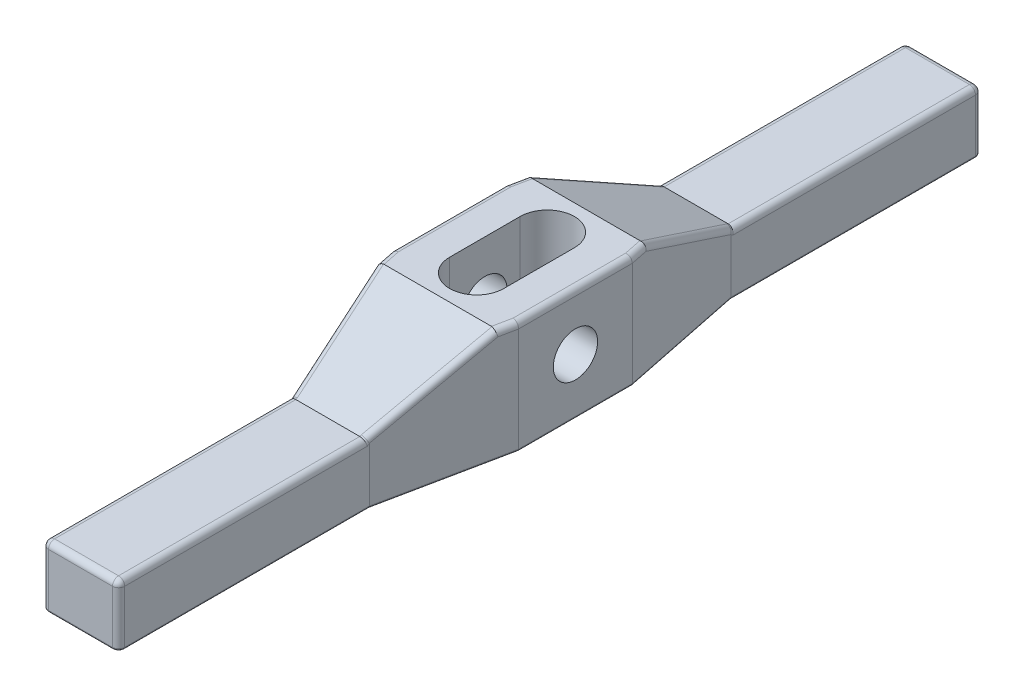
from build123d import *

# Parameters (mm, degrees)
EXTRUDE1_DEPTH     = 28.067
CUT_EXTRUDE1_DEPTH = 32.75
SKETCH3_R          = 5.54355
CUT_EXTRUDE2_DEPTH = 32.75
FILLET1_R          = 1.524
FILLET2_R          = 0.508
FILLET3_R          = 1.524


with BuildPart() as part:
    # Sketch1 → Extrude1 (new body)
    with BuildSketch(Plane(origin=(0, 0, 0), x_dir=(1, 0, 0), z_dir=(0, 1, 0))):
        Polygon((-9.525, 107.95), (9.525, 107.95), (9.525, 45.212), (15.875, 14.224508), (15.875, -14.224508), (9.525, -45.212), (9.525, -107.95), (-9.525, -107.95), (-9.525, -45.212), (-15.875, -14.224508), (-15.875, 14.224508), (-9.525, 45.212), align=None)
        with BuildLine():
            Line((-6.7818, 8.8265), (-6.7818, -8.8265))
            ThreePointArc((-6.7818, -8.8265), (0, -15.6083), (6.7818, -8.8265))
            Line((6.7818, -8.8265), (6.7818, 8.8265))
            ThreePointArc((6.7818, 8.8265), (0, 15.6083), (-6.7818, 8.8265))
        make_face(mode=Mode.SUBTRACT)
    extrude(amount=EXTRUDE1_DEPTH)

    # Sketch2 → Cut-Extrude1 (cut, through all)
    with BuildSketch(Plane(origin=(15.875, 0, 0), x_dir=(0, 0, -1), z_dir=(1, 0, 0))):
        Polygon((107.95, 28.067), (18.5674, 28.067), (46.074990269, 15.24), (107.95, 15.24), align=None)
        Polygon((-107.95, 15.24), (-107.95, 28.067), (-18.5674, 28.067), (-46.074990269, 15.24), align=None)
    extrude(amount=-CUT_EXTRUDE1_DEPTH, mode=Mode.SUBTRACT)

    # Sketch3 → Cut-Extrude2 (cut, through all)
    with BuildSketch(Plane(origin=(15.875, 0, 0), x_dir=(0, 0, -1), z_dir=(1, 0, 0))):
        with Locations((0, 13.9446)):
            Circle(SKETCH3_R)
    extrude(amount=-CUT_EXTRUDE2_DEPTH, mode=Mode.SUBTRACT)

    # Fillet1
    fillet1_edges = [part.edges().sort_by_distance(p)[0] for p in [
        (-9.525, 7.62, -107.95),
        (9.525, 7.62, -107.95),
        (9.525, 7.62, 107.95),
        (-9.525, 7.62, 107.95),
    ]]
    fillet(fillet1_edges, radius=FILLET1_R)

    # Fillet2
    fillet2_edges = [part.edges().sort_by_distance(p)[0] for p in [
        (-9.525, 0, -75.819),
        (9.525, 0, 75.819),
        (0, 0, 107.95),
        (0, 0, -107.95),
        (-9.078630735, 0, 107.503630735),
        (12.7, 0, -29.718254),
        (9.078630735, 0, 107.503630735),
        (9.078630735, 0, -107.503630735),
        (-9.078630735, 0, -107.503630735),
        (15.875, 0, 0),
        (12.7, 0, 29.718254),
        (-9.525, 0, 75.819),
        (-12.7, 0, 29.718254),
        (-15.875, 0, 0),
        (-12.7, 0, -29.718254),
        (9.525, 0, -75.819),
    ]]
    fillet(fillet2_edges, radius=FILLET2_R)

    # Fillet3
    fillet3_edges = [part.edges().sort_by_distance(p)[0] for p in [
        (0, 15.24, -107.95),
        (9.525, 15.24, -76.250495135),
        (9.078630735, 15.24, -107.503630735),
        (-9.078630735, 15.24, -107.503630735),
        (0, 15.24, 107.95),
        (-9.525, 15.24, 76.250495135),
        (-9.078630735, 15.24, 107.503630735),
        (9.078630735, 15.24, 107.503630735),
        (-15.875, 28.067, 0),
        (-15.430024263, 28.067, 16.395954),
        (15.875, 28.067, 0),
        (15.430024263, 28.067, -16.395954),
        (12.255024263, 21.854709486, -31.8897),
        (-15.430024263, 28.067, -16.395954),
        (-9.525, 15.24, -76.250495135),
        (-12.255024263, 21.854709486, -31.8897),
        (-9.525, 15.441209486, -45.643495135),
        (9.525, 15.441209486, -45.643495135),
        (15.430024263, 28.067, 16.395954),
        (12.255024263, 21.854709486, 31.8897),
        (9.525, 15.24, 76.250495135),
        (-9.525, 15.441209486, 45.643495135),
        (-12.255024263, 21.854709486, 31.8897),
        (9.525, 15.441209486, 45.643495135),
    ]]
    fillet(fillet3_edges, radius=FILLET3_R)


solid = part.part
